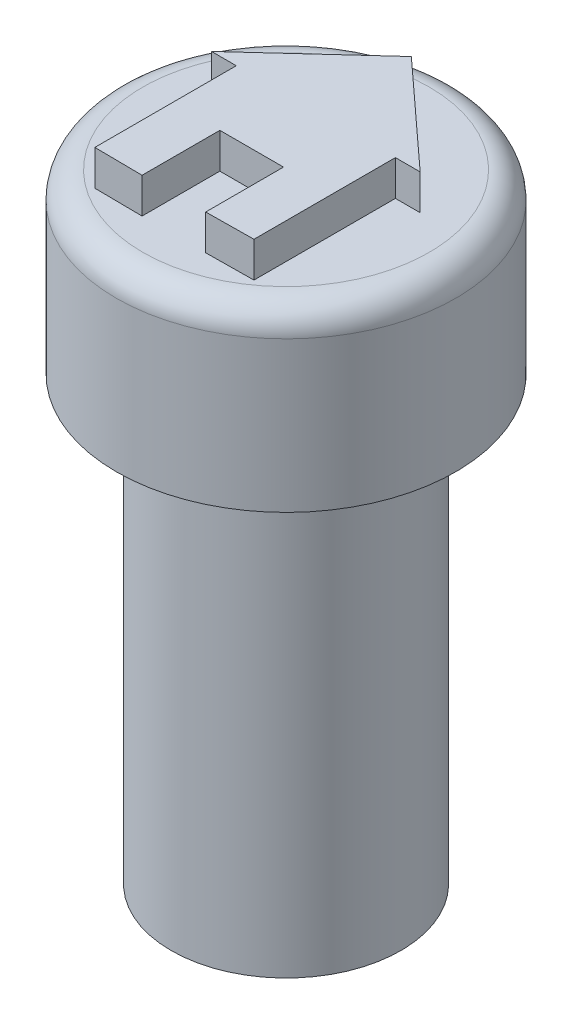
from build123d import *

# Parameters (mm, degrees)
SKETCH1_R           = 3.25
BOSS_EXTRUDE1_DEPTH = 12.5
SKETCH2_R           = 1.75
CUT_EXTRUDE1_DEPTH  = 2.5
SKETCH6_R           = 4.8
BOSS_EXTRUDE2_DEPTH = 5
BOSS_EXTRUDE3_DEPTH = 1
FILLET1_R           = 0.75


with BuildPart() as part:
    # Sketch1 → Boss-Extrude1 (new body)
    with BuildSketch(Plane(origin=(0, 0, 0), x_dir=(1, 0, 0), z_dir=(0, 1, 0))):
        Circle(SKETCH1_R)
    extrude(amount=BOSS_EXTRUDE1_DEPTH)

    # Sketch2 → Cut-Extrude1 (cut)
    with BuildSketch(Plane.XZ):
        Circle(SKETCH2_R)
    extrude(amount=-CUT_EXTRUDE1_DEPTH, mode=Mode.SUBTRACT)

    # Sketch6 → Boss-Extrude2 (add)
    with BuildSketch(Plane(origin=(0, 12.5, 0), x_dir=(1, 0, 0), z_dir=(0, 1, 0))):
        Circle(SKETCH6_R)
    extrude(amount=BOSS_EXTRUDE2_DEPTH)

    # Sketch12 → Boss-Extrude3 (add)
    with BuildSketch(Plane(origin=(0, 17.5, 0), x_dir=(1, 0, 0), z_dir=(0, 1, 0))):
        Polygon((0, 3.542487974), (-2.95, 0.842487974), (-2.25, 0.842487974), (-2.25, -3.157512026), (-0.9, -3.172366953), (-0.9, -0.972366953), (0.9, -0.972366953), (0.9, -3.172366953), (2.25, -3.157512026), (2.25, 0.842487974), (2.95, 0.842487974), align=None)
    extrude(amount=BOSS_EXTRUDE3_DEPTH)

    # Fillet1
    fillet1_edges = [part.edges().sort_by_distance(p)[0] for p in [
        (-4.8, 17.5, 0),
    ]]
    fillet(fillet1_edges, radius=FILLET1_R)


solid = part.part
